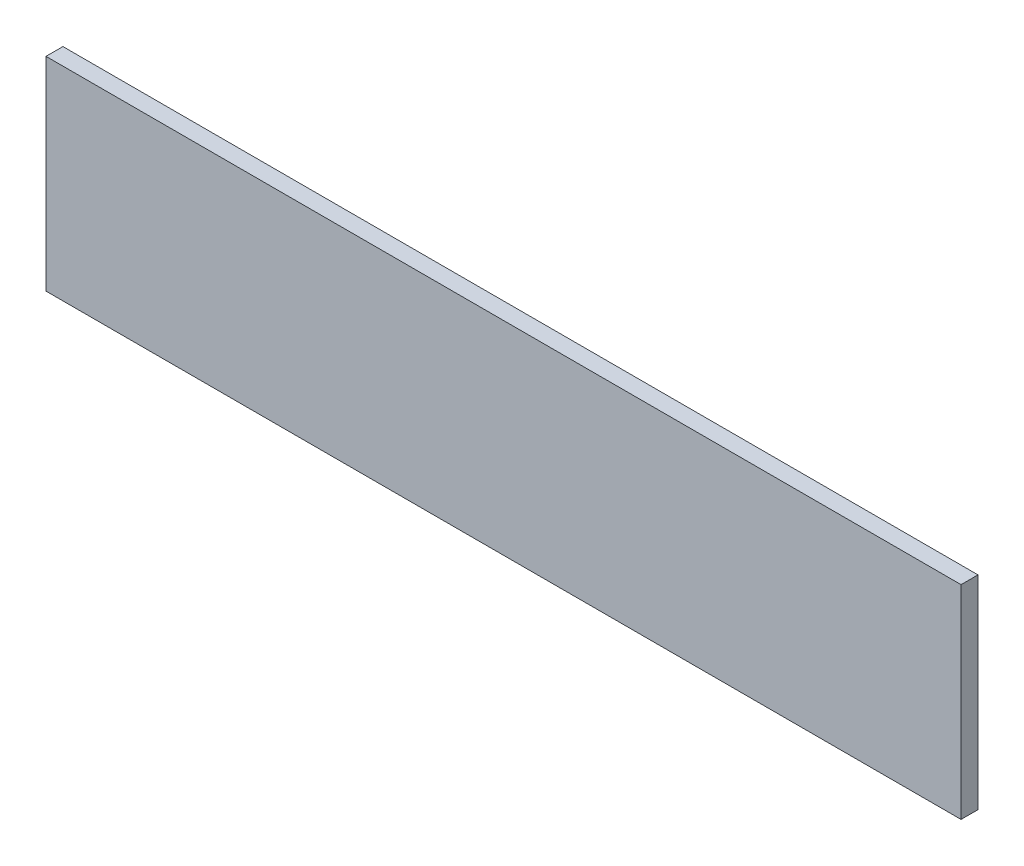
from build123d import *

# Parameters (mm, degrees)
SKETCH1_W           = 685.8
SKETCH1_H           = 152.4
BOSS_EXTRUDE1_DEPTH = 12.7


with BuildPart() as part:
    # Sketch1 → Boss-Extrude1 (new body)
    with BuildSketch(Plane.XY):
        Rectangle(SKETCH1_W, SKETCH1_H)
    extrude(amount=BOSS_EXTRUDE1_DEPTH)


solid = part.part
